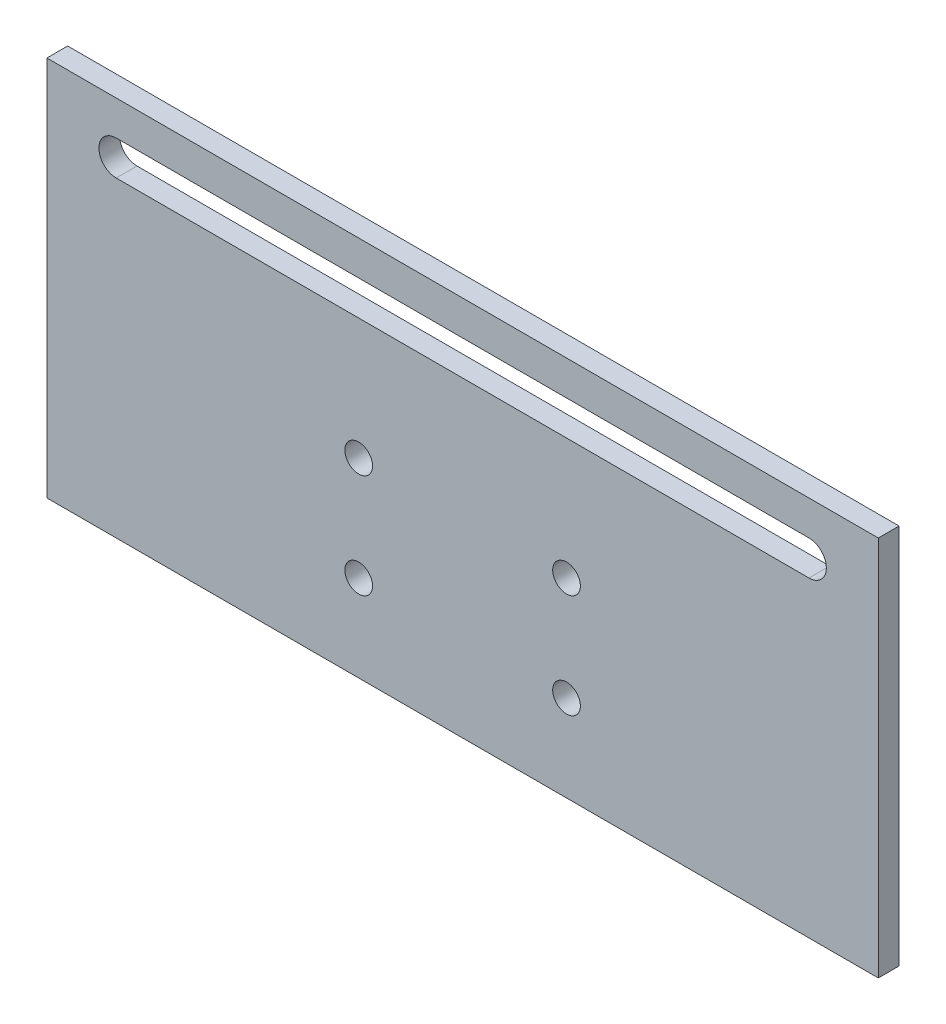
from build123d import *

# Parameters (mm, degrees)
SKETCH1_W           = 120
SKETCH1_H           = 55
SKETCH1_R           = 2
BOSS_EXTRUDE1_DEPTH = 1.5


with BuildPart() as part:
    # Sketch1 → Boss-Extrude1 (new body, symmetric)
    with BuildSketch(Plane.XY):
        Rectangle(SKETCH1_W, SKETCH1_H)
        with Locations((-15, 0)):
            Circle(SKETCH1_R, mode=Mode.SUBTRACT)
        with Locations((15, 0)):
            Circle(SKETCH1_R, mode=Mode.SUBTRACT)
        with Locations((15, -15)):
            Circle(SKETCH1_R, mode=Mode.SUBTRACT)
        with Locations((-15, -15)):
            Circle(SKETCH1_R, mode=Mode.SUBTRACT)
        with BuildLine():
            Line((-50, 22.5), (50, 22.5))
            ThreePointArc((50, 22.5), (52.5, 20), (50, 17.5))
            Line((50, 17.5), (-50, 17.5))
            ThreePointArc((-50, 17.5), (-52.5, 20), (-50, 22.5))
        make_face(mode=Mode.SUBTRACT)
    extrude(amount=BOSS_EXTRUDE1_DEPTH, both=True)


solid = part.part
